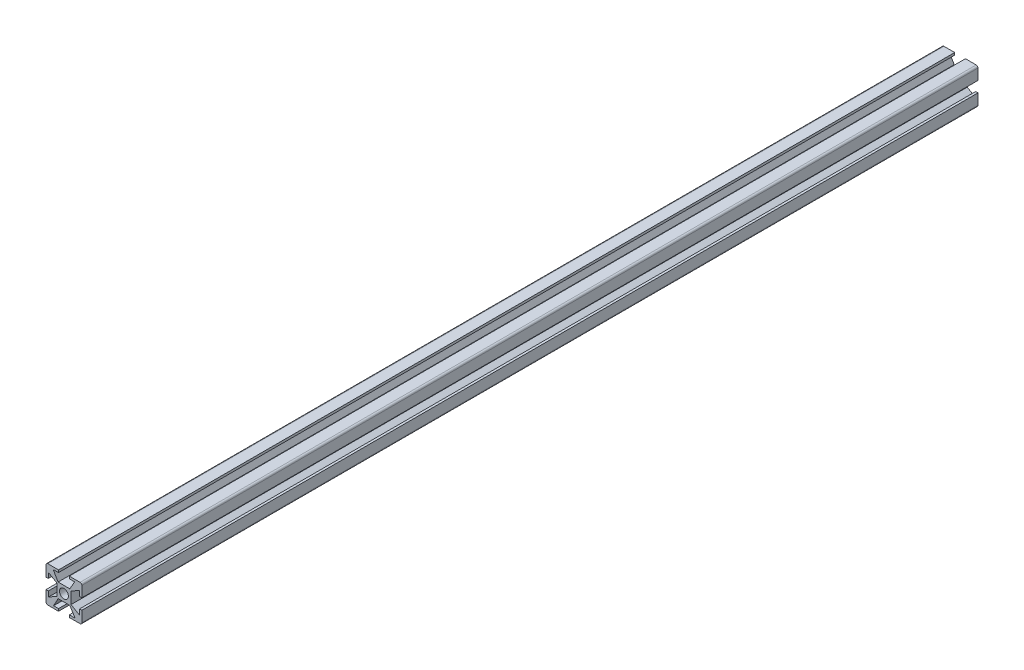
from build123d import *

# Parameters (mm, degrees)
CROQUIS1_W              = 8
CROQUIS1_H              = 8
CROQUIS1_R              = 2.5
SALIENTE_EXTRUIR4_DEPTH = 500


with BuildPart() as part:
    # Croquis1 → Saliente-Extruir4 (new body)
    with BuildSketch(Plane.XY):
        with BuildLine():
            Line((-3, 8.7), (-3, 10))
            Line((-3, 10), (-9, 10))
            ThreePointArc((-9, 10), (-9.707106781, 9.707106781), (-10, 9))
            Line((-10, 9), (-10, 3))
            Line((-10, 3), (-8.7, 3))
            Line((-8.7, 3), (-8.7, 6))
            Line((-8.7, 6), (-4, 3.25))
            Line((-4, 3.25), (-4, 4))
            Line((-4, 4), (-3.25, 4))
            Line((-3.25, 4), (-6, 8.7))
            Line((-6, 8.7), (-3, 8.7))
        make_face()
        with BuildLine():
            Line((9, 10), (3, 10))
            Line((3, 10), (3, 8.7))
            Line((3, 8.7), (6, 8.7))
            Line((6, 8.7), (3.25, 4))
            Line((3.25, 4), (4, 4))
            Line((4, 4), (4, 3.25))
            Line((4, 3.25), (8.7, 6))
            Line((8.7, 6), (8.7, 3))
            Line((8.7, 3), (10, 3))
            Line((10, 3), (10, 9))
            ThreePointArc((10, 9), (9.707106781, 9.707106781), (9, 10))
        make_face()
        with BuildLine():
            Line((10, -9), (10, -3))
            Line((10, -3), (8.7, -3))
            Line((8.7, -3), (8.7, -6))
            Line((8.7, -6), (4, -3.25))
            Line((4, -3.25), (4, -4))
            Line((4, -4), (3.25, -4))
            Line((3.25, -4), (6.25, -8.7))
            Line((6.25, -8.7), (3, -8.7))
            Line((3, -8.7), (3, -10))
            Line((3, -10), (9, -10))
            ThreePointArc((9, -10), (9.707106781, -9.707106781), (10, -9))
        make_face()
        with BuildLine():
            Line((-8.7, -3), (-10, -3))
            Line((-10, -3), (-10, -9))
            ThreePointArc((-10, -9), (-9.707106781, -9.707106781), (-9, -10))
            Line((-9, -10), (-3, -10))
            Line((-3, -10), (-3, -8.7))
            Line((-3, -8.7), (-5.75, -8.7))
            Line((-5.75, -8.7), (-3.25, -4))
            Line((-3.25, -4), (-4, -4))
            Line((-4, -4), (-4, -3.25))
            Line((-4, -3.25), (-8.7, -6))
            Line((-8.7, -6), (-8.7, -3))
        make_face()
        Rectangle(CROQUIS1_W, CROQUIS1_H)
        Circle(CROQUIS1_R, mode=Mode.SUBTRACT)
    extrude(amount=SALIENTE_EXTRUIR4_DEPTH)


solid = part.part
